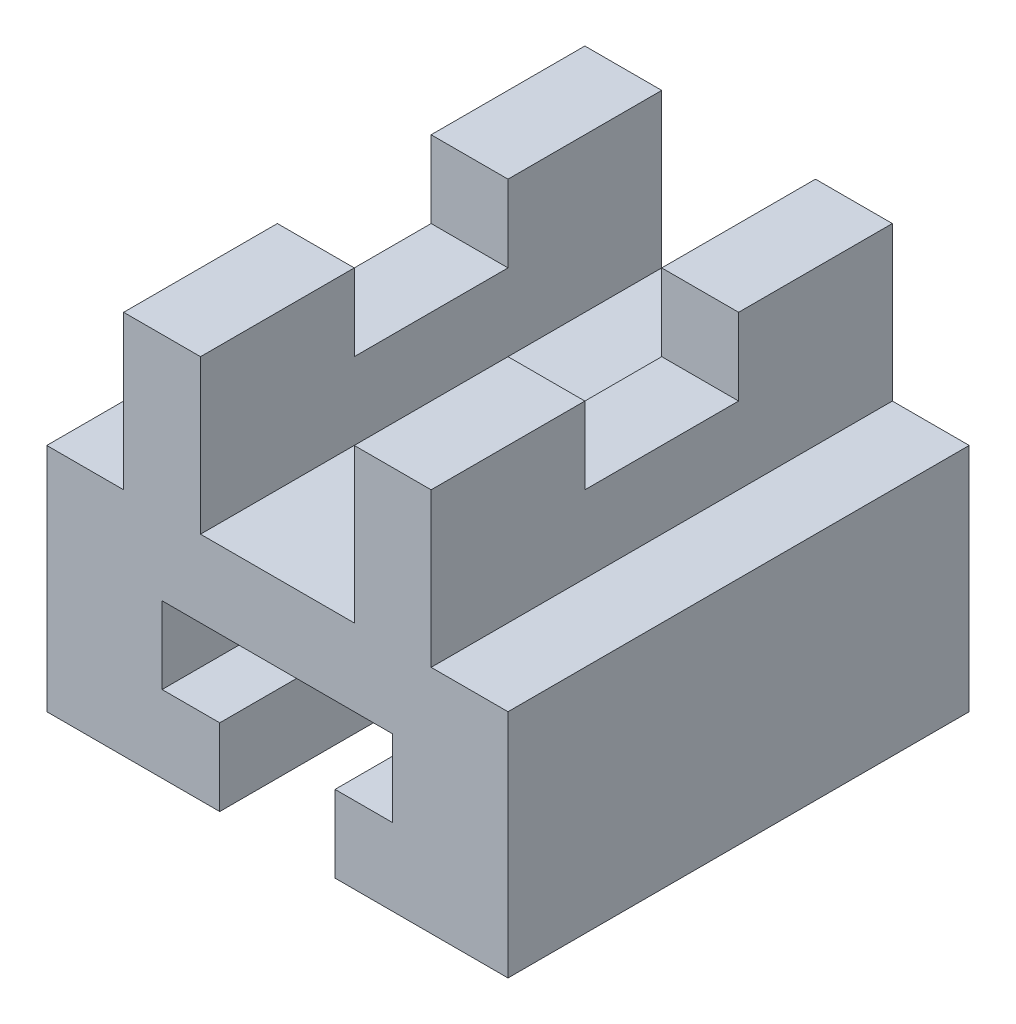
from build123d import *

# Parameters (mm, degrees)
BOSS_EXTRUDE1_DEPTH = 60
CUT_EXTRUDE1_DEPTH  = 84.666002653


with BuildPart() as part:
    # Sketch1 → Boss-Extrude1 (new body)
    with BuildSketch(Plane.XY):
        Polygon((-20.346054892, 0), (9.653945108, 0), (9.653945108, -10), (2.153945108, -10), (2.153945108, -20), (24.653945108, -20), (24.653945108, 10), (14.653945108, 10), (14.653945108, 30), (4.653945108, 30), (4.653945108, 10), (-15.346054892, 10), (-15.346054892, 30), (-25.346054892, 30), (-25.346054892, 10), (-35.346054892, 10), (-35.346054892, -20), (-12.846054892, -20), (-12.846054892, -10), (-20.346054892, -10), align=None)
    extrude(amount=BOSS_EXTRUDE1_DEPTH)

    # Sketch2 → Cut-Extrude1 (cut, through all)
    with BuildSketch(Plane(origin=(14.653945108, 0, 0), x_dir=(0, 0, -1), z_dir=(1, 0, 0))):
        Polygon((-20, 30), (-30, 30), (-40, 30), (-40, 20), (-20, 20), align=None)
    extrude(amount=-CUT_EXTRUDE1_DEPTH, mode=Mode.SUBTRACT)


solid = part.part
